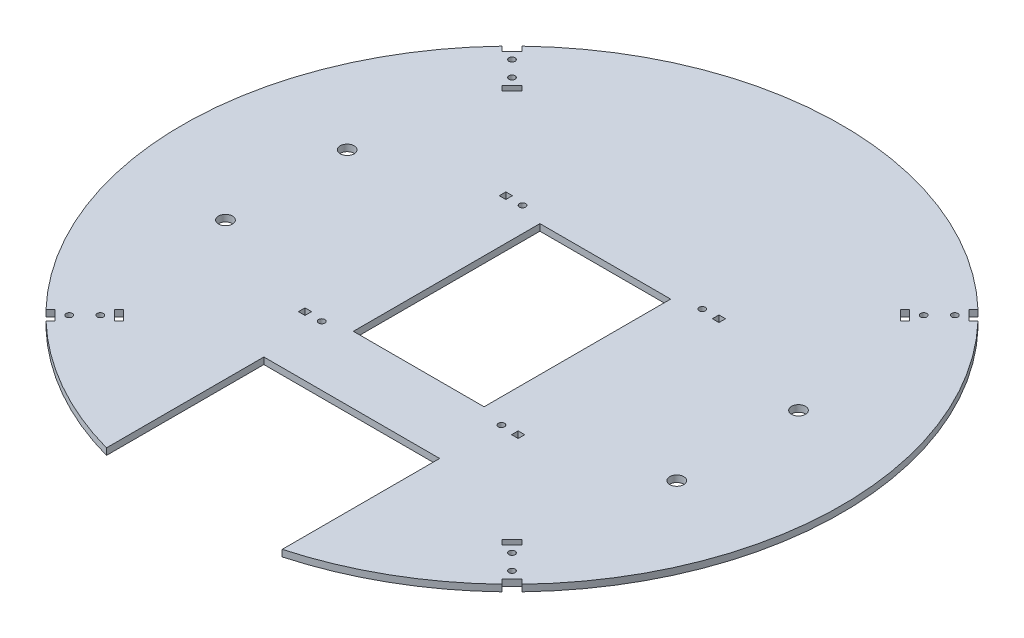
from build123d import *

# Parameters (mm, degrees)
SKETCH1_R           = 150
SKETCH1_W           = 59.5
SKETCH1_H           = 84.9
BOSS_EXTRUDE1_DEPTH = 3
SKETCH3_R           = 1.4224
SKETCH3_R_2         = 3.175
SKETCH3_W           = 3
SKETCH3_H           = 3
CUT_EXTRUDE1_DEPTH  = 10
SKETCH6_W           = 80
SKETCH6_H           = 88.399519522
CUT_EXTRUDE3_DEPTH  = 3
SKETCH8_R           = 1.4224
CUT_EXTRUDE5_DEPTH  = 3


with BuildPart() as part:
    # Sketch1 → Boss-Extrude1 (new body)
    with BuildSketch(Plane(origin=(0, 0, 0), x_dir=(1, 0, 0), z_dir=(0, 1, 0))):
        Circle(SKETCH1_R)
        Rectangle(SKETCH1_W, SKETCH1_H, mode=Mode.SUBTRACT)
    extrude(amount=BOSS_EXTRUDE1_DEPTH)

    # Sketch3 → Cut-Extrude1 (cut)
    with BuildSketch(Plane(origin=(0, 3, 0), x_dir=(1, 0, 0), z_dir=(0, 1, 0))):
        with Locations((-40.9, 45.7)):
            Circle(SKETCH3_R)
        with Locations((40.9, 45.7)):
            Circle(SKETCH3_R)
        with Locations((40.9, -45.7)):
            Circle(SKETCH3_R)
        with Locations((-40.9, -45.7)):
            Circle(SKETCH3_R)
        with Locations((-102.7, 27.7)):
            Circle(SKETCH3_R_2)
        with Locations((-102.7, -27.7)):
            Circle(SKETCH3_R_2)
        with Locations((102.7, 27.7)):
            Circle(SKETCH3_R_2)
        with Locations((102.7, -27.7)):
            Circle(SKETCH3_R_2)
        with Locations((-48.5, 45.7)):
            Rectangle(SKETCH3_W, SKETCH3_H)
        with Locations((48.5, 45.7)):
            Rectangle(SKETCH3_W, SKETCH3_H)
        with Locations((48.5, -45.7)):
            Rectangle(SKETCH3_W, SKETCH3_H)
        with Locations((-48.5, -45.7)):
            Rectangle(SKETCH3_W, SKETCH3_H)
    extrude(amount=-CUT_EXTRUDE1_DEPTH, mode=Mode.SUBTRACT)

    # Sketch6 → Cut-Extrude3 (cut)
    with BuildSketch(Plane(origin=(0, 3, 0), x_dir=(1, 0, 0), z_dir=(0, 1, 0))):
        with Locations((0, -117.129759761)):
            Rectangle(SKETCH6_W, SKETCH6_H)
    extrude(amount=-CUT_EXTRUDE3_DEPTH, mode=Mode.SUBTRACT)

    # Sketch8 → Cut-Extrude5 (cut)
    with BuildSketch(Plane.XZ):
        with Locations((100.762716319, 100.762716319)):
            Circle(SKETCH8_R)
        with Locations((93.691648507, 93.691648507)):
            Circle(SKETCH8_R)
        with Locations((100.762716319, -100.762716319)):
            Circle(SKETCH8_R)
        with Locations((93.691648507, -93.691648507)):
            Circle(SKETCH8_R)
        with Locations((-100.762716319, -100.762716319)):
            Circle(SKETCH8_R)
        with Locations((-93.691648507, -93.691648507)):
            Circle(SKETCH8_R)
        with Locations((-100.762716319, 100.762716319)):
            Circle(SKETCH8_R)
        with Locations((-93.691648507, 93.691648507)):
            Circle(SKETCH8_R)
        Polygon((90.633411679, 86.143283618), (92.754732022, 88.264603962), (88.264603962, 92.754732022), (86.143283618, 90.633411679), align=None)
        Polygon((103.820953148, 108.311081208), (108.311081208, 103.820953148), (106.189760865, 101.699632804), (101.699632804, 106.189760865), align=None)
        Polygon((86.143283618, -90.633411679), (88.264603962, -92.754732022), (92.754732022, -88.264603962), (90.633411679, -86.143283618), align=None)
        Polygon((108.311081208, -103.820953148), (103.820953148, -108.311081208), (101.699632804, -106.189760865), (106.189760865, -101.699632804), align=None)
        Polygon((-90.633411679, -86.143283618), (-92.754732022, -88.264603962), (-88.264603962, -92.754732022), (-86.143283618, -90.633411679), align=None)
        Polygon((-103.820953148, -108.311081208), (-108.311081208, -103.820953148), (-106.189760865, -101.699632804), (-101.699632804, -106.189760865), align=None)
        Polygon((-86.143283618, 90.633411679), (-88.264603962, 92.754732022), (-92.754732022, 88.264603962), (-90.633411679, 86.143283618), align=None)
        Polygon((-108.311081208, 103.820953148), (-103.820953148, 108.311081208), (-101.699632804, 106.189760865), (-106.189760865, 101.699632804), align=None)
    extrude(amount=-CUT_EXTRUDE5_DEPTH, mode=Mode.SUBTRACT)


solid = part.part
